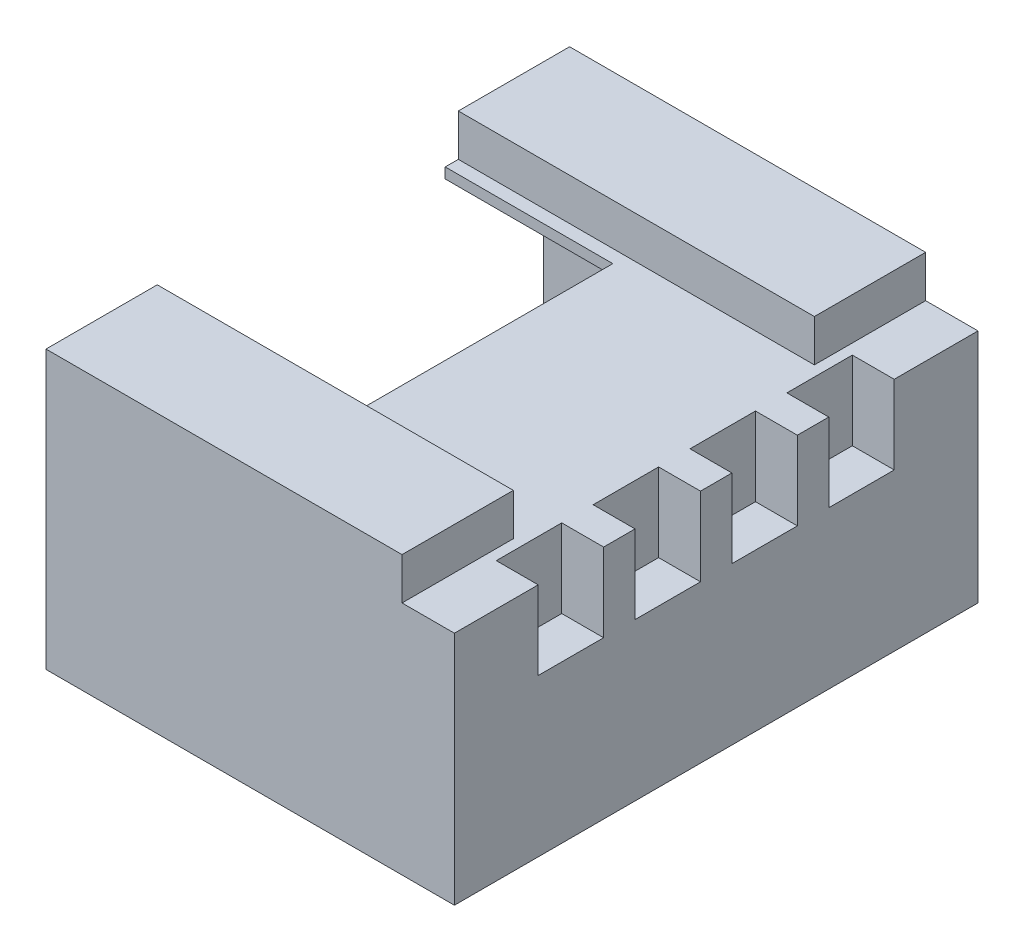
from build123d import *

# Parameters (mm, degrees)
ESQUISSE7_W                = 4
ESQUISSE7_H                = 0.3
BOSS_EXTRU_2_DEPTH         = 0.3
ESQUISSE12_W               = 7.8
ESQUISSE12_H               = 10
BOSS_EXTRU_3_DEPTH         = 5.3
ENL_V_MAT_EXTRU_3_DEPTH    = 6.1
ESQUISSE14_W               = 3.2
ESQUISSE14_H               = 5.25
ENL_V_MAT_EXTRU_4_DEPTH    = 1
R_P_TITION_LIN_AIRE1_COUNT = 4
R_P_TITION_LIN_AIRE1_PITCH = 2.3
ESQUISSE15_W               = 3.397317762
ESQUISSE15_H               = 5.75
ENL_V_MAT_EXTRU_5_DEPTH    = 0.8
ESQUISSE16_W               = 9.511143681
ESQUISSE16_H               = 5.75
ENL_V_MAT_EXTRU_6_DEPTH    = 0.8
ESQUISSE17_W               = 2.077305242
ESQUISSE17_H               = 10.679300776
ENL_V_MAT_EXTRU_7_DEPTH    = 0.8
ESQUISSE18_W               = 1.3
ESQUISSE18_H               = 1.25
ENL_V_MAT_EXTRU_8_DEPTH    = 1.5


with BuildPart() as part:
    # Esquisse7 → Boss.-Extru.2 (new body)
    with BuildSketch(Plane(origin=(0, 0, -3.6), x_dir=(-1, 0, 0), z_dir=(0, 0, -1))):
        with Locations((-5.55, 3.25)):
            Rectangle(ESQUISSE7_W, ESQUISSE7_H)
    boss_extru_2 = extrude(amount=-BOSS_EXTRU_2_DEPTH)


with BuildPart() as body_2:
    # Esquisse12 → Boss.-Extru.3 (new body)
    with BuildSketch(Plane(origin=(0, 6.05, 0), x_dir=(1, 0, 0), z_dir=(0, 1, 0))):
        with Locations((5.35, 0)):
            Rectangle(ESQUISSE12_W, ESQUISSE12_H)
    extrude(amount=-BOSS_EXTRU_3_DEPTH)

    # Esquisse13 → Enlèv. mat.-Extru.3 (cut)
    with BuildSketch(Plane.ZY.offset(-1.45)):
        Polygon((-4.5, 5.55), (-4.5, 1.25), (4.5, 1.25), (4.5, 5.55), (3.5, 5.55), (3.5, 5.05), (-3.5, 5.05), (-3.5, 5.55), align=None)
    extrude(amount=-ENL_V_MAT_EXTRU_3_DEPTH, mode=Mode.SUBTRACT)

    # Esquisse14 → Enlèv. mat.-Extru.4 (cut)
    with BuildSketch(Plane(origin=(0, 6.05, 0), x_dir=(-1, 0, 0), z_dir=(0, 1, 0))):
        with Locations((-3.05, 0)):
            Rectangle(ESQUISSE14_W, ESQUISSE14_H)
    extrude(amount=-ENL_V_MAT_EXTRU_4_DEPTH, mode=Mode.SUBTRACT)

    # Esquisse15 → Enlèv. mat.-Extru.5 (cut)
    with BuildSketch(Plane(origin=(0, 6.05, 0), x_dir=(1, 0, 0), z_dir=(0, 1, 0))):
        with Locations((2.951341119, 0)):
            Rectangle(ESQUISSE15_W, ESQUISSE15_H)
    extrude(amount=-ENL_V_MAT_EXTRU_5_DEPTH, mode=Mode.SUBTRACT)

    # Esquisse16 → Enlèv. mat.-Extru.6 (cut)
    with BuildSketch(Plane(origin=(0, 6.05, 0), x_dir=(1, 0, 0), z_dir=(0, 1, 0))):
        with Locations((6.205571841, 0)):
            Rectangle(ESQUISSE16_W, ESQUISSE16_H)
    extrude(amount=-ENL_V_MAT_EXTRU_6_DEPTH, mode=Mode.SUBTRACT)

    # Esquisse17 → Enlèv. mat.-Extru.7 (cut)
    with BuildSketch(Plane(origin=(0, 6.05, 0), x_dir=(1, 0, 0), z_dir=(0, 1, 0))):
        with Locations((9.288652621, 0.006970823)):
            Rectangle(ESQUISSE17_W, ESQUISSE17_H)
    extrude(amount=-ENL_V_MAT_EXTRU_7_DEPTH, mode=Mode.SUBTRACT)

    # Esquisse18 → Enlèv. mat.-Extru.8 (cut)
    with BuildSketch(Plane(origin=(0, 5.25, 0), x_dir=(1, 0, 0), z_dir=(0, 1, 0))):
        with Locations((9.1, 0.925)):
            Rectangle(ESQUISSE18_W, ESQUISSE18_H)
        with Locations((9.1, 2.775)):
            Rectangle(ESQUISSE18_W, ESQUISSE18_H)
        with Locations((9.1, -2.775)):
            Rectangle(ESQUISSE18_W, ESQUISSE18_H)
        with Locations((9.1, -0.925)):
            Rectangle(ESQUISSE18_W, ESQUISSE18_H)
    extrude(amount=-ENL_V_MAT_EXTRU_8_DEPTH, mode=Mode.SUBTRACT)


with BuildPart() as r_p_tition_lin_aire1_1:
    # Répétition linéaire1: Boss.-Extru.2 ×4
    with Locations(*[(0, 0, i * R_P_TITION_LIN_AIRE1_PITCH) for i in range(1, R_P_TITION_LIN_AIRE1_COUNT)]):
        add(boss_extru_2)


solid = Compound([part.part, body_2.part, r_p_tition_lin_aire1_1.part])
